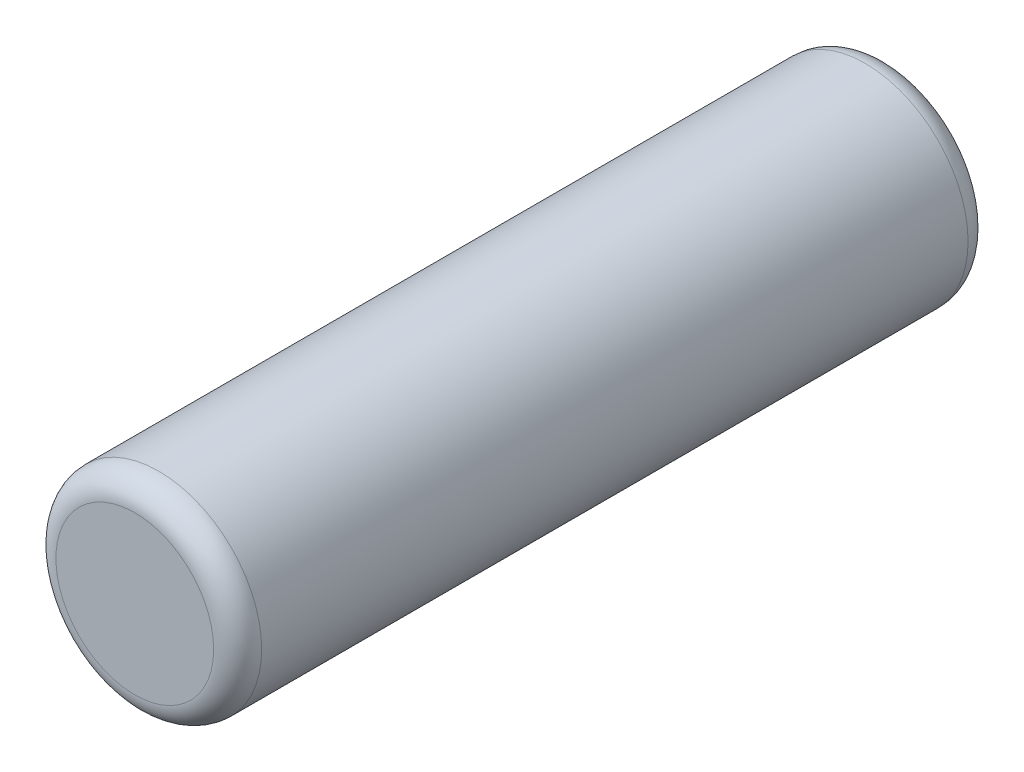
from build123d import *

# Parameters (mm, degrees)
SKETCH1_R           = 1.5
BOSS_EXTRUDE1_DEPTH = 5.5
FILLET1_R           = 0.35


with BuildPart() as part:
    # Sketch1 → Boss-Extrude1 (new body, symmetric)
    with BuildSketch(Plane.XY):
        Circle(SKETCH1_R)
    extrude(amount=BOSS_EXTRUDE1_DEPTH, both=True)

    # Fillet1
    fillet1_edges = [part.edges().sort_by_distance(p)[0] for p in [
        (-1.5, 0, -5.5),
        (-1.5, 0, 5.5),
    ]]
    fillet(fillet1_edges, radius=FILLET1_R)


solid = part.part
